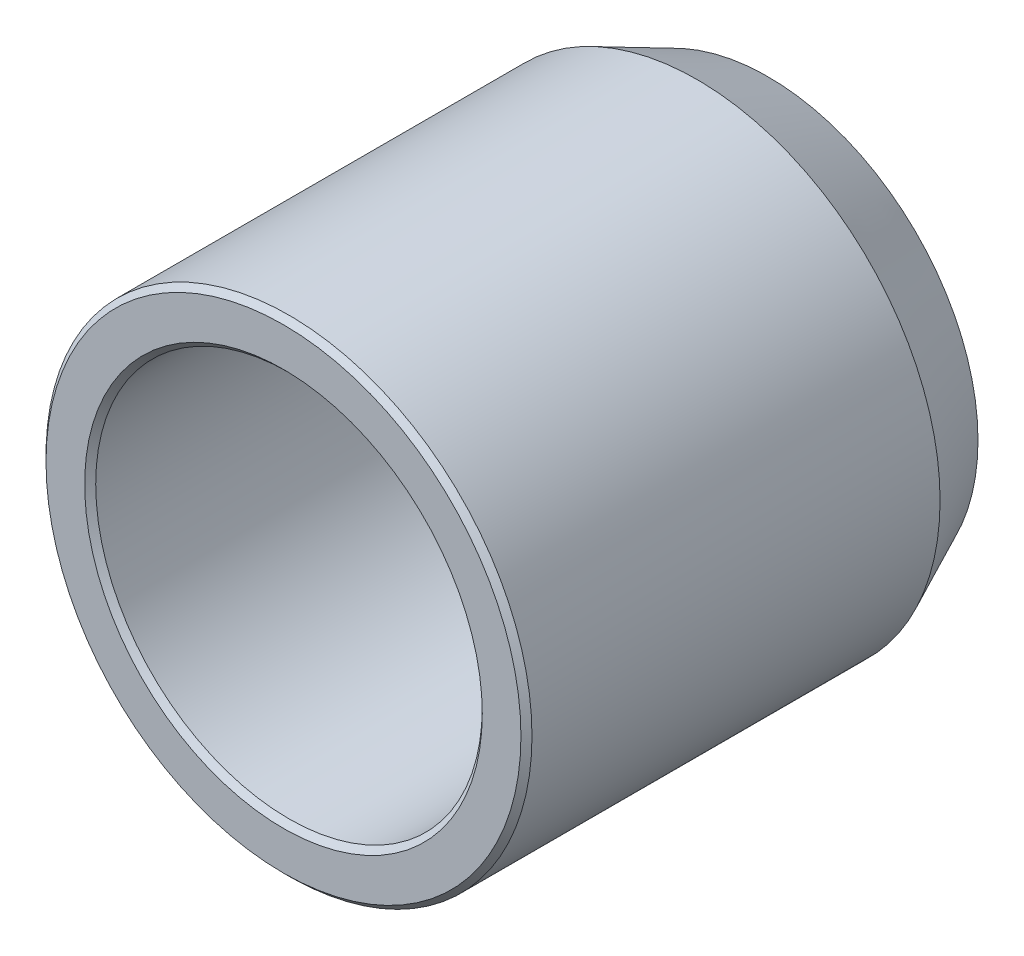
from build123d import *


with BuildPart() as part:
    # Szkic2 → Obrót1 (revolve)
    with BuildSketch(Plane(origin=(0, 0, 0), x_dir=(0, 0, -1), z_dir=(1, 0, 0))):
        Polygon((0, 18), (0, 21.5), (0.5, 22), (37.446479238, 22), (43.88, 19), (43.88, 16), (39.38, 16), (38.88, 16.5), (38.88, 17.5), (0.5, 17.5), align=None)
    revolve(axis=Axis((0, 0, 0), (0, 0, -1)))


solid = part.part
